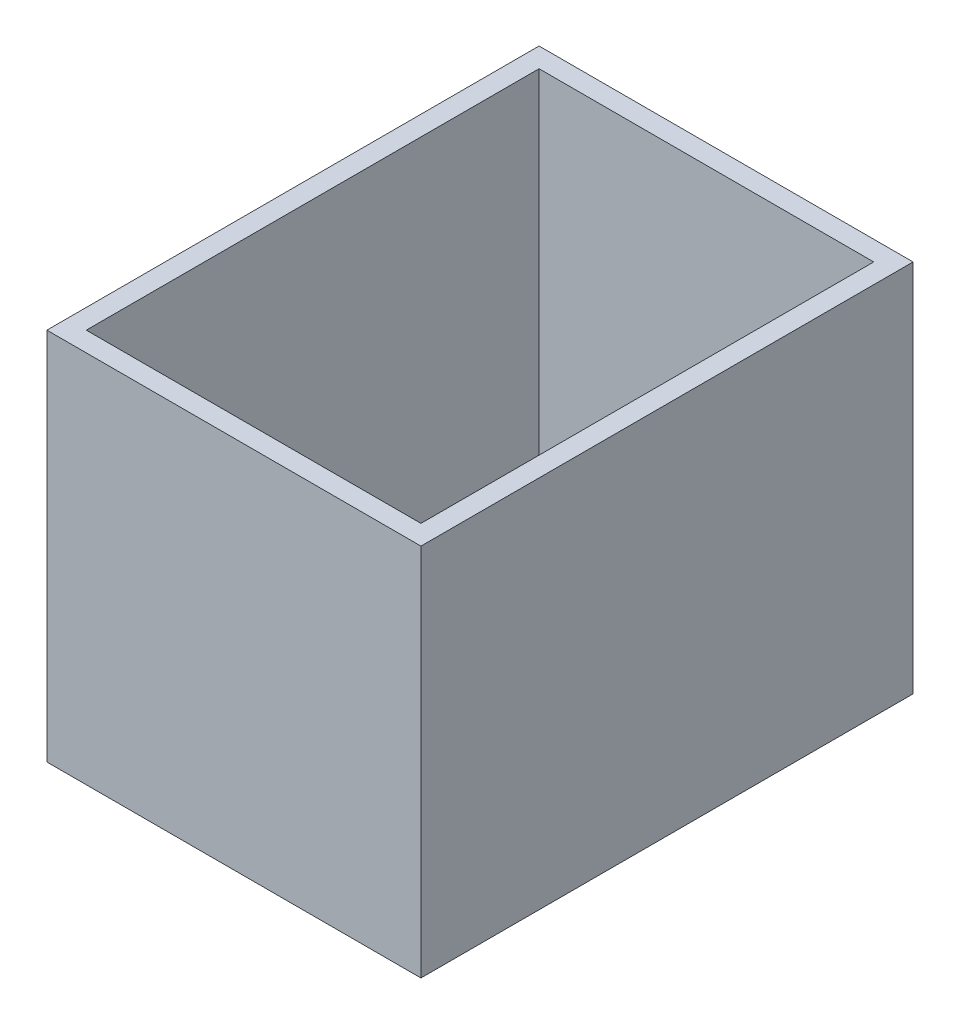
from build123d import *

# Parameters (mm, degrees)
SKETCH2_W           = 96.52
SKETCH2_H           = 96.52
BOSS_EXTRUDE1_DEPTH = 127
SKETCH3_W           = 86.36
SKETCH3_H           = 116.84
CUT_EXTRUDE1_DEPTH  = 91.44


with BuildPart() as part:
    # Sketch2 → Boss-Extrude1 (new body)
    with BuildSketch(Plane.XY):
        with Locations((60.154945376, -16.002480847)):
            Rectangle(SKETCH2_W, SKETCH2_H)
    extrude(amount=BOSS_EXTRUDE1_DEPTH)

    # Sketch3 → Cut-Extrude1 (cut)
    with BuildSketch(Plane(origin=(0, 32.257519153, 0), x_dir=(1, 0, 0), z_dir=(0, 1, 0))):
        with Locations((60.154945376, -63.5)):
            Rectangle(SKETCH3_W, SKETCH3_H)
    extrude(amount=-CUT_EXTRUDE1_DEPTH, mode=Mode.SUBTRACT)


solid = part.part
